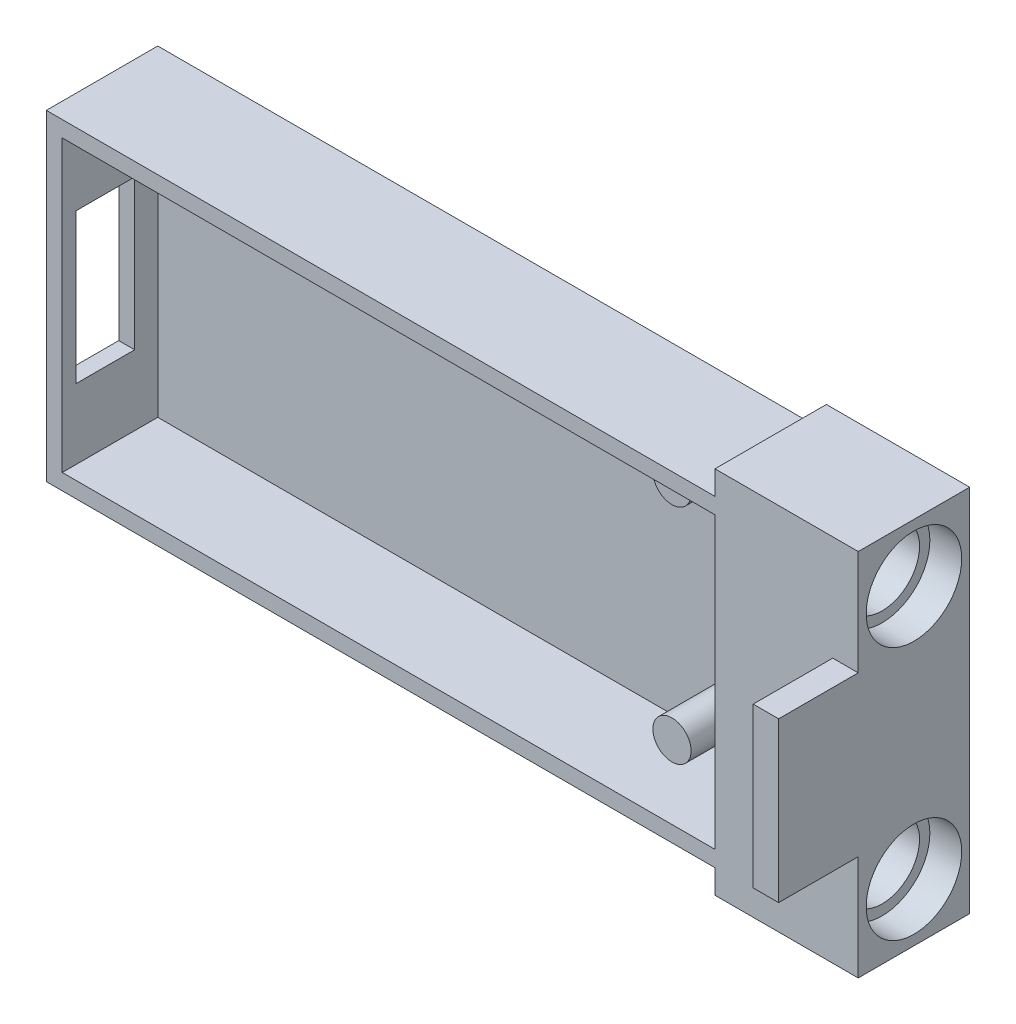
from build123d import *

# Parameters (mm, degrees)
SKETCH1_W              = 39
SKETCH1_H              = 20.2
BOSS_EXTRUDE1_DEPTH    = 7
SKETCH2_W              = 38
SKETCH2_H              = 18.2
CUT_EXTRUDE1_DEPTH     = 6
SKETCH3_R              = 1.2
SPUNT_DEPTH            = 3.5
SKETCH5_W              = 3.7
SKETCH5_H              = 9.4
USBC_DEPTH             = 22
ROZSIRENI_DRZAKU_DEPTH = 3
SKETCH7_W              = 7
SKETCH7_H              = 23.2
DRZAK_DEPTH            = 9
SKETCH8_R              = 2.35
ZAKLADNI_DIRA_DEPTH    = 9
SKETCH9_R              = 3
CUT_EXTRUDE4_DEPTH     = 2
SKETCH11_R             = 3
CUT_EXTRUDE5_DEPTH     = 1
SKETCH10_W             = 1.6
SKETCH10_H             = 10
PODSTAVA_DEPTH         = 5


with BuildPart() as part:
    # Sketch1 → Boss-Extrude1 (new body)
    with BuildSketch(Plane.XY):
        Rectangle(SKETCH1_W, SKETCH1_H)
    extrude(amount=BOSS_EXTRUDE1_DEPTH)

    # Sketch2 → Cut-Extrude1 (cut)
    with BuildSketch(Plane.XY.offset(7)):
        with Locations((0.5, 0)):
            Rectangle(SKETCH2_W, SKETCH2_H)
    extrude(amount=-CUT_EXTRUDE1_DEPTH, mode=Mode.SUBTRACT)

    # Sketch3 → spunt (add)
    with BuildSketch(Plane.XY.offset(1)):
        with Locations((17.3, -7)):
            Circle(SKETCH3_R)
        with Locations((17.3, 7)):
            Circle(SKETCH3_R)
    extrude(amount=SPUNT_DEPTH)

    # Sketch5 → usbc (cut)
    with BuildSketch(Plane(origin=(-18.5, 0, 0), x_dir=(0, 0, -1), z_dir=(1, 0, 0))):
        with Locations((-4.3, 0)):
            Rectangle(SKETCH5_W, SKETCH5_H)
    extrude(amount=-USBC_DEPTH, mode=Mode.SUBTRACT)

    # Sketch6 → rozsireni drzaku (add)
    with BuildSketch(Plane(origin=(19.5, 0, 0), x_dir=(0, 0, -1), z_dir=(1, 0, 0))):
        Polygon((-7, -10.1), (0, -10.1), (0, 10.1), (-7, 10.1), (-7, 9.1), (-1, 9.1), (-1, -9.1), (-7, -9.1), align=None)
    extrude(amount=ROZSIRENI_DRZAKU_DEPTH)

    # Sketch7 → drzak (add)
    with BuildSketch(Plane(origin=(22.5, 0, 0), x_dir=(0, 0, -1), z_dir=(1, 0, 0))):
        with Locations((-3.5, 0)):
            Rectangle(SKETCH7_W, SKETCH7_H)
    extrude(amount=DRZAK_DEPTH)

    # Sketch8 → zakladni dira (cut)
    with BuildSketch(Plane(origin=(31.5, 0, 0), x_dir=(0, 0, -1), z_dir=(1, 0, 0))):
        with Locations((-3.5, 7.97)):
            Circle(SKETCH8_R)
        with Locations((-3.5, -7.97)):
            Circle(SKETCH8_R)
    extrude(amount=-ZAKLADNI_DIRA_DEPTH, mode=Mode.SUBTRACT)

    # Sketch9 → Cut-Extrude4 (cut)
    with BuildSketch(Plane(origin=(31.5, 0, 0), x_dir=(0, 0, -1), z_dir=(1, 0, 0))):
        with Locations((-3.5, 7.97)):
            Circle(SKETCH9_R)
        with Locations((-3.5, -7.97)):
            Circle(SKETCH9_R)
    extrude(amount=-CUT_EXTRUDE4_DEPTH, mode=Mode.SUBTRACT)

    # Sketch11 → Cut-Extrude5 (cut)
    with BuildSketch(Plane.ZY.offset(-22.5)):
        with Locations((3.5, -7.97)):
            Circle(SKETCH11_R)
        with Locations((3.5, 7.97)):
            Circle(SKETCH11_R)
    extrude(amount=-CUT_EXTRUDE5_DEPTH, mode=Mode.SUBTRACT)

    # Sketch10 → podstava (add)
    with BuildSketch(Plane.XY.offset(7)):
        with Locations((30.7, 0)):
            Rectangle(SKETCH10_W, SKETCH10_H)
    extrude(amount=PODSTAVA_DEPTH)


solid = part.part
